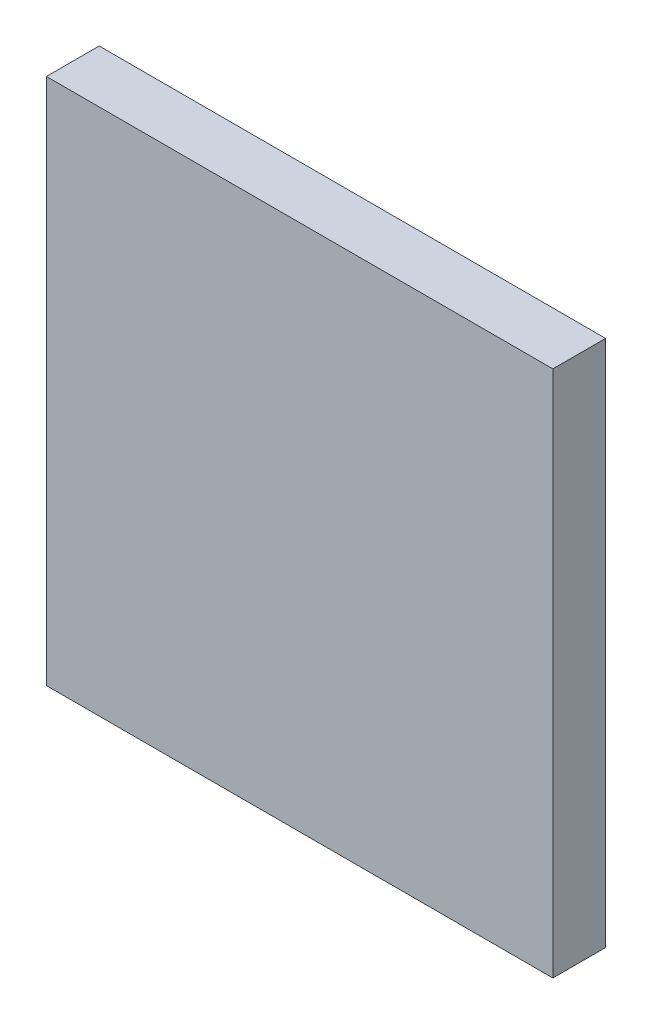
from build123d import *

# Parameters (mm, degrees)
SKETCH1_W           = 240
SKETCH1_H           = 250
BOSS_EXTRUDE1_DEPTH = 25


with BuildPart() as part:
    # Sketch1 → Boss-Extrude1 (new body)
    with BuildSketch(Plane.XY):
        with Locations((120, 125)):
            Rectangle(SKETCH1_W, SKETCH1_H)
    extrude(amount=BOSS_EXTRUDE1_DEPTH)


solid = part.part
